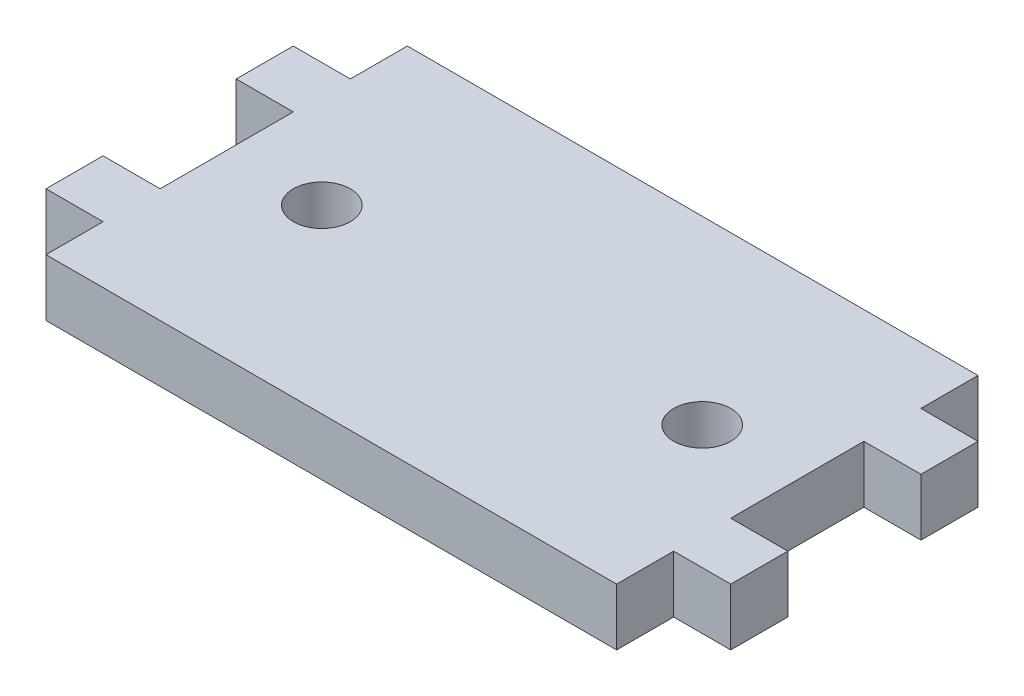
from build123d import *

# Parameters (mm, degrees)
SKETCH1_R           = 1.5
BOSS_EXTRUDE1_DEPTH = 3


with BuildPart() as part:
    # Sketch1 → Boss-Extrude1 (new body)
    with BuildSketch(Plane(origin=(0, 0, 0), x_dir=(1, 0, 0), z_dir=(0, 1, 0))):
        Polygon((-42.867412192, 7), (-42.867412192, 10), (-39.867412192, 10), (-39.867412192, 13), (-9.867412192, 13), (-9.867412192, 10), (-6.867412192, 10), (-6.867412192, 7), (-9.867412192, 7), (-9.867412192, 0), (-6.867412192, 0), (-6.867412192, -3), (-9.867412192, -3), (-9.867412192, -6), (-39.867412192, -6), (-39.867412192, -3), (-42.867412192, -3), (-42.867412192, 0), (-39.867412192, 0), (-39.867412192, 7), align=None)
        with Locations((-34.867412192, 3.5)):
            Circle(SKETCH1_R, mode=Mode.SUBTRACT)
        with Locations((-14.867412192, 3.5)):
            Circle(SKETCH1_R, mode=Mode.SUBTRACT)
    extrude(amount=BOSS_EXTRUDE1_DEPTH)


solid = part.part
